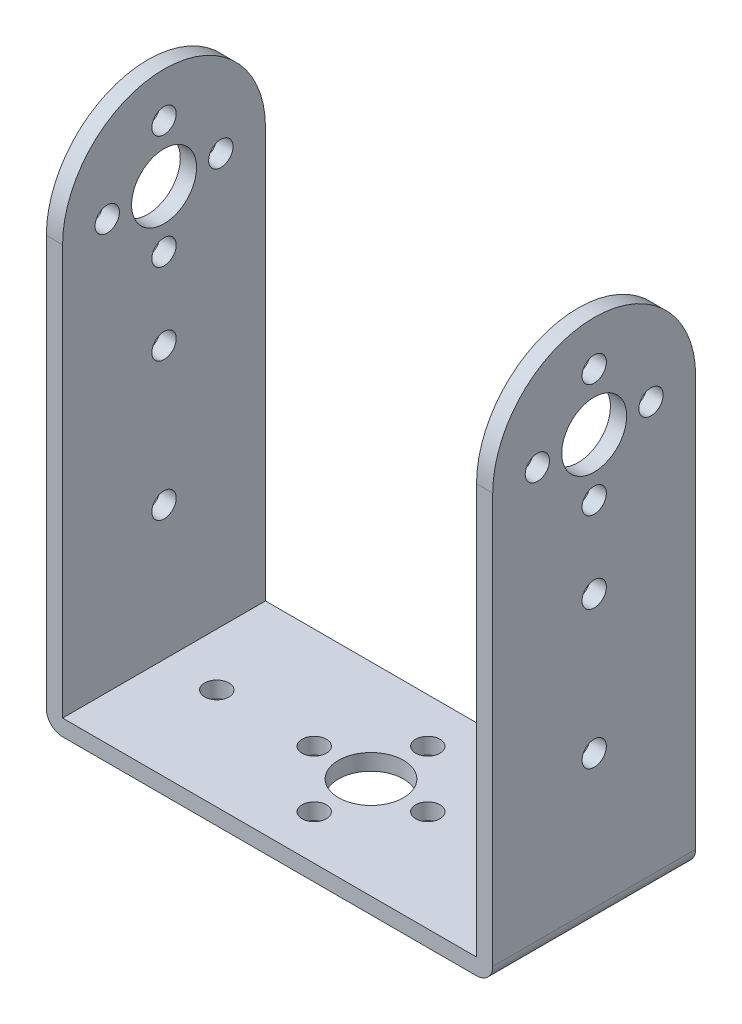
from build123d import *

# Parameters (mm, degrees)
ESTRUSIONE_ESTRUSIONE1_DEPTH  = 25
RACCORDO1_R                   = 2
RACCORDO2_R                   = 2
TAGLIO_ESTRUSIONE5_DEPTH      = 70.574089891
TAGLIO_ESTRUSIONE5_DEPTH_BACK = 70.574089891
TAGLIO_ESTRUSIONE6_DEPTH      = 70.574089891
TAGLIO_ESTRUSIONE6_DEPTH_BACK = 70.574089891
SCHIZZO8_9_R                  = 4
SCHIZZO8_9_R_2                = 1.5
TAGLIO_ESTRUSIONE7_DEPTH      = 84.473852071
TAGLIO_ESTRUSIONE7_DEPTH_BACK = 84.473852071
SCHIZZO11_R                   = 4
SCHIZZO11_R_2                 = 1.5


with BuildPart() as part:
    # Schizzo4 → Estrusione-Estrusione1 (new body)
    with BuildSketch(Plane.XY):
        Polygon((-48.72252025, 30.495594714), (-48.72252025, -34.504405286), (6.27747975, -34.504405286), (6.27747975, 30.495594714), (4.27747975, 30.495594714), (4.27747975, -32.504405286), (-46.72252025, -32.504405286), (-46.72252025, 30.495594714), align=None)
    extrude(amount=ESTRUSIONE_ESTRUSIONE1_DEPTH)

    # Raccordo1
    raccordo1_edges = [part.edges().sort_by_distance(p)[0] for p in [
        (6.27747975, -34.504405286, 12.5),
    ]]
    fillet(raccordo1_edges, radius=RACCORDO1_R)

    # Raccordo2
    raccordo2_edges = [part.edges().sort_by_distance(p)[0] for p in [
        (-48.72252025, -34.504405286, 12.5),
    ]]
    fillet(raccordo2_edges, radius=RACCORDO2_R)

    # Schizzo8 → Taglio-Estrusione5 (cut, two sides: drawn at the far end of the back side and taken through both)
    with BuildSketch(Plane(origin=(6.27747975, 0, 0), x_dir=(0, 0, -1), z_dir=(1, 0, 0)).offset(-TAGLIO_ESTRUSIONE5_DEPTH_BACK)):
        with BuildLine():
            Line((-12.5, 30.495594714), (-25, 30.495594714))
            Line((-25, 30.495594714), (-25, 17.995594714))
            ThreePointArc((-25, 17.995594714), (-21.338834765, 26.834429478), (-12.5, 30.495594714))
        make_face()
        with BuildLine():
            Line((0, 30.495594714), (-12.5, 30.495594714))
            ThreePointArc((-12.5, 30.495594714), (-3.661165235, 26.834429478), (0, 17.995594714))
            Line((0, 17.995594714), (0, 30.495594714))
        make_face()
    extrude(amount=TAGLIO_ESTRUSIONE5_DEPTH + TAGLIO_ESTRUSIONE5_DEPTH_BACK, mode=Mode.SUBTRACT)

    # Schizzo8_9 → Taglio-Estrusione6 (cut, two sides: drawn at the far end of the back side and taken through both)
    with BuildSketch(Plane(origin=(6.27747975, 0, 0), x_dir=(0, 0, -1), z_dir=(1, 0, 0)).offset(-TAGLIO_ESTRUSIONE6_DEPTH_BACK)):
        with Locations((-12.5, 17.995594714)):
            Circle(SCHIZZO8_9_R)
        with Locations((-5.5, 17.995594714)):
            Circle(SCHIZZO8_9_R_2)
        with Locations((-12.5, 24.995594714)):
            Circle(SCHIZZO8_9_R_2)
        with Locations((-19.5, 17.995594714)):
            Circle(SCHIZZO8_9_R_2)
        with Locations((-12.5, 0.995594714)):
            Circle(SCHIZZO8_9_R_2)
        with Locations((-12.5, -16.004405286)):
            Circle(SCHIZZO8_9_R_2)
        with Locations((-12.5, 10.995594714)):
            Circle(SCHIZZO8_9_R_2)
    extrude(amount=TAGLIO_ESTRUSIONE6_DEPTH + TAGLIO_ESTRUSIONE6_DEPTH_BACK, mode=Mode.SUBTRACT)

    # Schizzo11 → Taglio-Estrusione7 (cut, two sides: drawn at the far end of the back side and taken through both)
    with BuildSketch(Plane(origin=(0, -32.504405286, 0), x_dir=(1, 0, 0), z_dir=(0, 1, 0)).offset(-TAGLIO_ESTRUSIONE7_DEPTH_BACK)):
        with Locations((-21.22252025, -12.5)):
            Circle(SCHIZZO11_R)
        with Locations((-21.22252025, -5.5)):
            Circle(SCHIZZO11_R_2)
        with Locations((-28.22252025, -12.5)):
            Circle(SCHIZZO11_R_2)
        with Locations((-21.22252025, -19.5)):
            Circle(SCHIZZO11_R_2)
        with Locations((-14.22252025, -12.5)):
            Circle(SCHIZZO11_R_2)
        with Locations((-2.22252025, -12.5)):
            Circle(SCHIZZO11_R_2)
        with Locations((-40.22252025, -12.5)):
            Circle(SCHIZZO11_R_2)
    extrude(amount=TAGLIO_ESTRUSIONE7_DEPTH + TAGLIO_ESTRUSIONE7_DEPTH_BACK, mode=Mode.SUBTRACT)


solid = part.part
